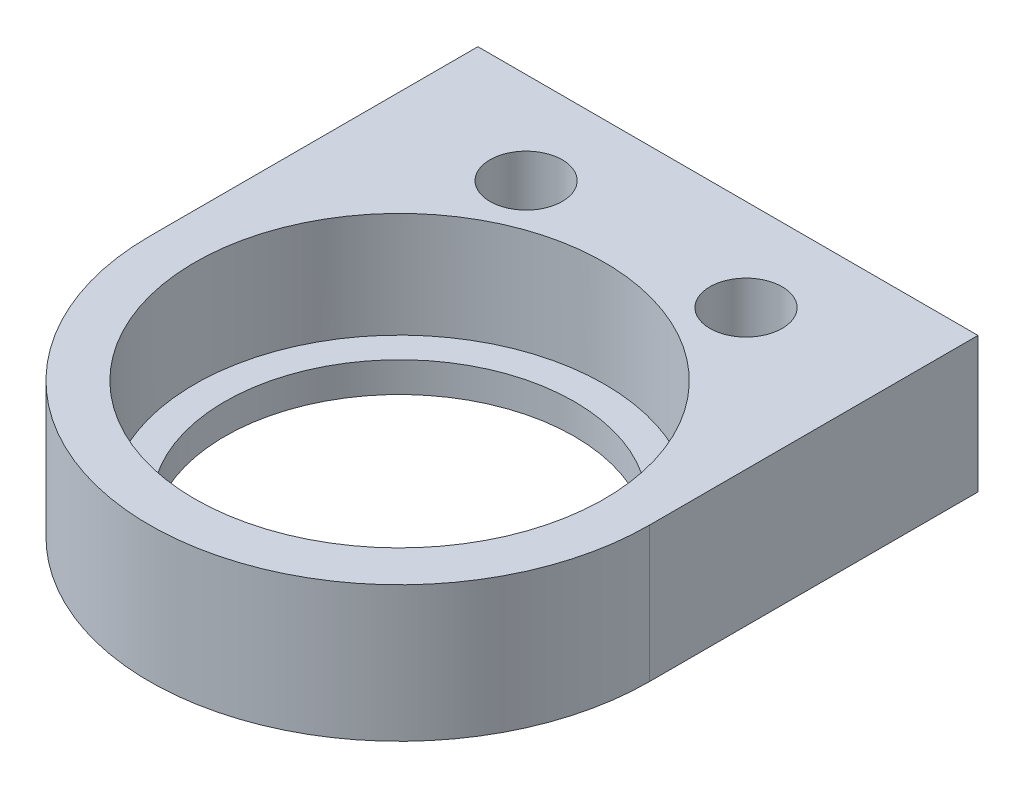
from build123d import *

# Parameters (mm, degrees)
SKETCH1_R           = 6.096
BOSS_EXTRUDE1_DEPTH = 4.445
SKETCH5_R           = 7.366
BOSS_EXTRUDE4_DEPTH = 1.27
SKETCH8_R           = 8.636
CUT_EXTRUDE4_DEPTH  = 4.445
SKETCH6_R           = 1.524
CUT_EXTRUDE2_DEPTH  = 6.715
SKETCH7_W           = 9.525
SKETCH7_H           = 4.445
CUT_EXTRUDE3_DEPTH  = 3.175


with BuildPart() as part:
    # Sketch1 → Boss-Extrude1 (new body)
    with BuildSketch(Plane(origin=(0, 0, 0), x_dir=(1, 0, 0), z_dir=(0, 1, 0))):
        with BuildLine():
            Line((-10.541, 0), (-10.541, 10.668))
            Line((-10.541, 10.668), (-20.066, 10.668))
            Line((-20.066, 10.668), (-20.066, 13.843))
            Line((-20.066, 13.843), (-7.366, 13.843))
            Line((-7.366, 13.843), (7.366, 13.843))
            Line((7.366, 13.843), (20.066, 13.843))
            Line((20.066, 13.843), (20.066, 10.668))
            Line((20.066, 10.668), (10.541, 10.668))
            Line((10.541, 10.668), (10.541, 0))
            ThreePointArc((10.541, 0), (0, -10.541), (-10.541, 0))
        make_face()
        Circle(SKETCH1_R, mode=Mode.SUBTRACT)
    extrude(amount=BOSS_EXTRUDE1_DEPTH)

    # Sketch5 → Boss-Extrude4 (add)
    with BuildSketch(Plane.XZ):
        with BuildLine():
            Line((-10.541, 0), (-10.541, -10.668))
            Line((-10.541, -10.668), (-10.541, -13.843))
            Line((-10.541, -13.843), (10.541, -13.843))
            Line((10.541, -13.843), (10.541, -10.668))
            Line((10.541, -10.668), (10.541, 0))
            ThreePointArc((10.541, 0), (0, 10.541), (-10.541, 0))
        make_face()
        Circle(SKETCH5_R, mode=Mode.SUBTRACT)
    extrude(amount=BOSS_EXTRUDE4_DEPTH)

    # Sketch8 → Cut-Extrude4 (cut)
    with BuildSketch(Plane(origin=(0, 4.445, 0), x_dir=(1, 0, 0), z_dir=(0, 1, 0))):
        Circle(SKETCH8_R)
    extrude(amount=-CUT_EXTRUDE4_DEPTH, mode=Mode.SUBTRACT)

    # Sketch6 → Cut-Extrude2 (cut, through all)
    with BuildSketch(Plane(origin=(0, 4.445, 0), x_dir=(1, 0, 0), z_dir=(0, 1, 0))):
        with Locations((4.6355, 9.9695)):
            Circle(SKETCH6_R)
        with Locations((-4.6355, 9.9695)):
            Circle(SKETCH6_R)
    extrude(amount=-CUT_EXTRUDE2_DEPTH, mode=Mode.SUBTRACT)

    # Sketch7 → Cut-Extrude3 (cut)
    with BuildSketch(Plane.XY.offset(-10.668)):
        with Locations((15.3035, 2.2225)):
            Rectangle(SKETCH7_W, SKETCH7_H)
        with Locations((-15.3035, 2.2225)):
            Rectangle(SKETCH7_W, SKETCH7_H)
    extrude(amount=-CUT_EXTRUDE3_DEPTH, mode=Mode.SUBTRACT)


solid = part.part
